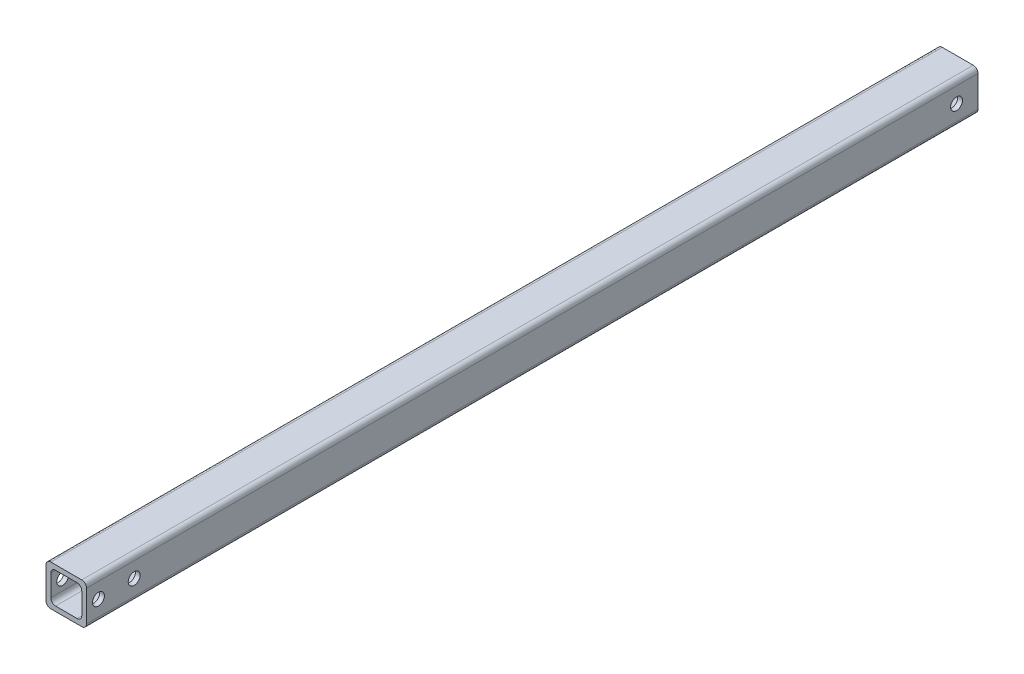
from build123d import *

# Parameters (mm, degrees)
SKETCH1_W      = 17
SKETCH1_H      = 17
EXTRUDE1_DEPTH = 374
FILLET2_R      = 2
SKETCH2_W      = 13
SKETCH2_H      = 13
EXTRUDE2_DEPTH = 375
FILLET3_R      = 2
SKETCH3_R      = 2.5
EXTRUDE3_DEPTH = 18


with BuildPart() as part:
    # Sketch1 → Extrude1 (new body)
    with BuildSketch(Plane.XY):
        with Locations((-39.634997969, 15.034639228)):
            Rectangle(SKETCH1_W, SKETCH1_H)
    extrude(amount=EXTRUDE1_DEPTH)

    # Fillet2
    fillet2_edges = [part.edges().sort_by_distance(p)[0] for p in [
        (-48.134997969, 23.534639228, 187),
        (-31.134997969, 23.534639228, 187),
        (-31.134997969, 6.534639228, 187),
        (-48.134997969, 6.534639228, 187),
    ]]
    fillet(fillet2_edges, radius=FILLET2_R)

    # Sketch2 → Extrude2 (cut, through all)
    with BuildSketch(Plane.XY.offset(374)):
        with Locations((-39.634997969, 15.034639228)):
            Rectangle(SKETCH2_W, SKETCH2_H)
    extrude(amount=-EXTRUDE2_DEPTH, mode=Mode.SUBTRACT)

    # Fillet3
    fillet3_edges = [part.edges().sort_by_distance(p)[0] for p in [
        (-46.134997969, 8.534639228, 187),
        (-46.134997969, 21.534639228, 187),
        (-33.134997969, 21.534639228, 187),
        (-33.134997969, 8.534639228, 187),
    ]]
    fillet(fillet3_edges, radius=FILLET3_R)

    # Sketch3 → Extrude3 (cut, through all)
    with BuildSketch(Plane(origin=(-31.134997969, 0, 0), x_dir=(0, 0, -1), z_dir=(1, 0, 0))):
        with Locations((-369, 15.034639228)):
            Circle(SKETCH3_R)
        with Locations((-354, 15.034639228)):
            Circle(SKETCH3_R)
        with Locations((-9, 15.034639228)):
            Circle(SKETCH3_R)
    extrude(amount=-EXTRUDE3_DEPTH, mode=Mode.SUBTRACT)


solid = part.part
